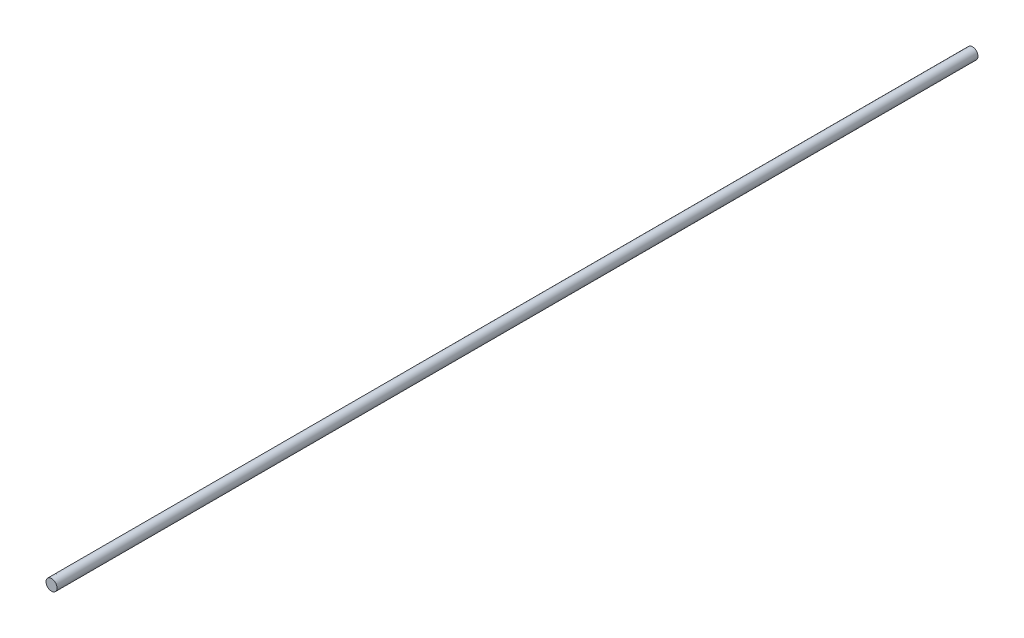
from build123d import *

# Parameters (mm, degrees)
SKETCH1_R           = 3
BOSS_EXTRUDE1_DEPTH = 250


with BuildPart() as part:
    # Sketch1 → Boss-Extrude1 (new body, symmetric)
    with BuildSketch(Plane.XY):
        Circle(SKETCH1_R)
    extrude(amount=BOSS_EXTRUDE1_DEPTH, both=True)


solid = part.part
